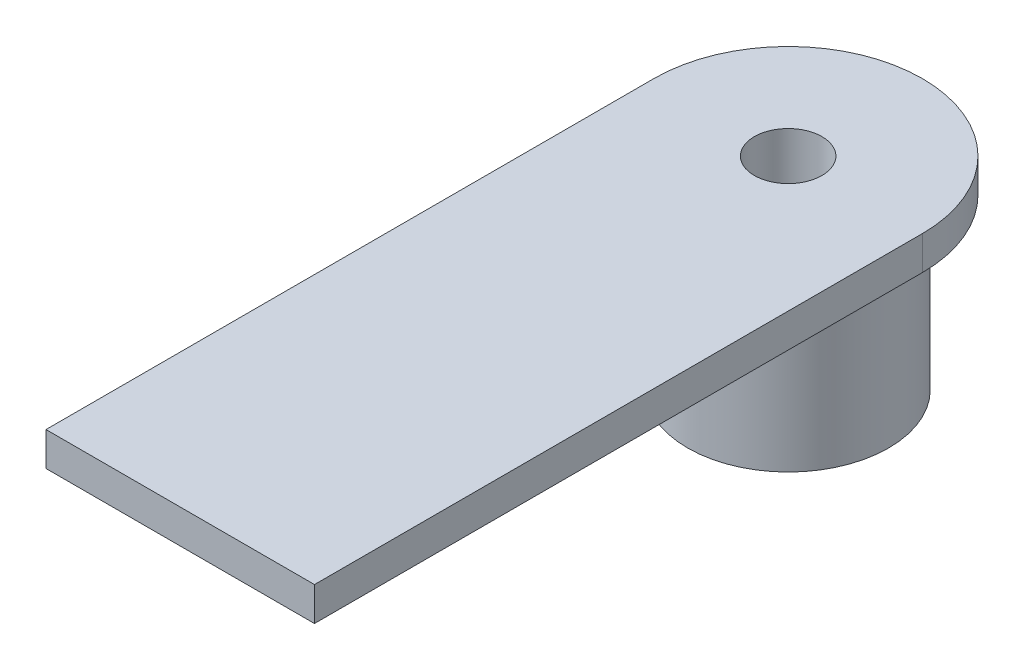
from build123d import *

# Parameters (mm, degrees)
SKETCH1_R           = 5.95
BOSS_EXTRUDE1_DEPTH = 10
BOSS_EXTRUDE2_DEPTH = 2
CHAMFER1_SIZE       = 1.5
CHAMFER1_SIZE2      = 0.346302287
SKETCH3_R           = 2
CUT_EXTRUDE1_DEPTH  = 13
SKETCH4_W           = 15.9
SKETCH4_H           = 2
BOSS_EXTRUDE3_DEPTH = 20


with BuildPart() as part:
    # Sketch1 → Boss-Extrude1 (new body)
    with BuildSketch(Plane(origin=(0, 0, 0), x_dir=(1, 0, 0), z_dir=(0, 1, 0))):
        Circle(SKETCH1_R)
    extrude(amount=BOSS_EXTRUDE1_DEPTH)

    # Sketch2 → Boss-Extrude2 (add)
    with BuildSketch(Plane(origin=(0, 10, 0), x_dir=(1, 0, 0), z_dir=(0, 1, 0))):
        with BuildLine():
            Line((-7.95, 0), (-7.95, -16))
            Line((-7.95, -16), (7.95, -16))
            Line((7.95, -16), (7.95, 0))
            ThreePointArc((7.95, 0), (0, 7.95), (-7.95, 0))
        make_face()
    extrude(amount=BOSS_EXTRUDE2_DEPTH)

    # Chamfer1
    chamfer1_edges = [part.edges().sort_by_distance(p)[0] for p in [
        (-5.95, 10, 0),
    ]]
    chamfer1_side = [part.faces().sort_by_distance(p)[0] for p in [
        (-5.95, 5, 0),
    ]]
    chamfer(chamfer1_edges, length=CHAMFER1_SIZE, length2=CHAMFER1_SIZE2, reference=chamfer1_side[0])

    # Sketch3 → Cut-Extrude1 (cut, through all)
    with BuildSketch(Plane.XZ):
        Circle(SKETCH3_R)
    extrude(amount=-CUT_EXTRUDE1_DEPTH, mode=Mode.SUBTRACT)

    # Sketch4 → Boss-Extrude3 (add)
    with BuildSketch(Plane.XY.offset(16)):
        with Locations((0, 11)):
            Rectangle(SKETCH4_W, SKETCH4_H)
    extrude(amount=BOSS_EXTRUDE3_DEPTH)


solid = part.part
